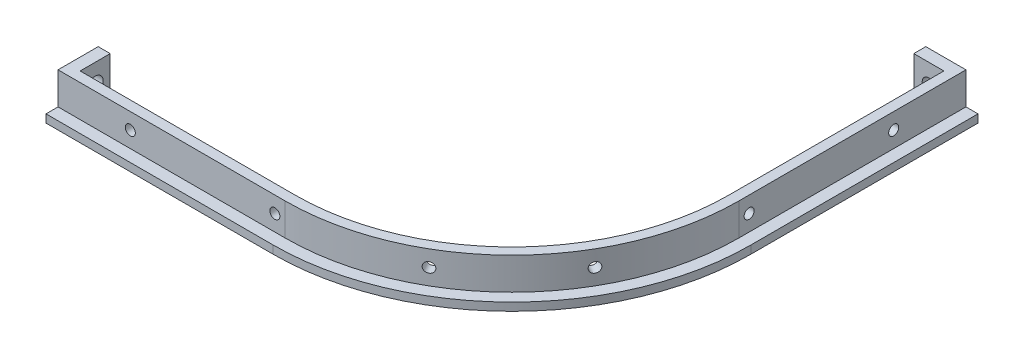
from build123d import *

# Parameters (mm, degrees)
BOSS_EXTRUDE1_DEPTH = 10
CUT_EXTRUDE1_START  = -1
SKETCH2_R           = 55.1
CUT_EXTRUDE1_DEPTH  = 1.1
CUT_EXTRUDE2_DEPTH  = 8
SKETCH4_R           = 2
CUT_EXTRUDE3_DEPTH  = 4
SKETCH5_R           = 1.65
CUT_EXTRUDE4_DEPTH  = 4
SKETCH7_R           = 1.25
CUT_EXTRUDE5_DEPTH  = 114.07
SKETCH9_R           = 1.25
CUT_EXTRUDE6_DEPTH  = 134.776057092


with BuildPart() as part:
    # Sketch1 → Boss-Extrude1 (new body)
    with BuildSketch(Plane(origin=(0, 0, 0), x_dir=(1, 0, 0), z_dir=(0, 1, 0))):
        with BuildLine():
            Line((0, -116.07), (56.57, -116.07))
            ThreePointArc((56.57, -116.07), (98.642853481, -98.642853481), (116.07, -56.57))
            Line((116.07, -56.57), (116.07, 0))
            Line((116.07, 0), (103.07, 0))
            Line((103.07, 0), (103.07, -3))
            Line((103.07, -3), (110.57, -3))
            Line((110.57, -3), (110.57, -56.57))
            ThreePointArc((110.57, -56.57), (94.753766184, -94.753766184), (56.57, -110.57))
            Line((56.57, -110.57), (3, -110.57))
            Line((3, -110.57), (3, -103.07))
            Line((3, -103.07), (0, -103.07))
            Line((0, -103.07), (0, -116.07))
        make_face()
    extrude(amount=BOSS_EXTRUDE1_DEPTH)

    # Sketch2 → Cut-Extrude1 (cut)
    with BuildSketch(Plane(origin=(0, 10, 0), x_dir=(1, 0, 0), z_dir=(0, 1, 0)).offset(CUT_EXTRUDE1_START)):
        with Locations((56.57, -56.57)):
            Circle(SKETCH2_R)
    extrude(amount=-CUT_EXTRUDE1_DEPTH, mode=Mode.SUBTRACT)

    # Sketch3 → Cut-Extrude2 (cut)
    with BuildSketch(Plane(origin=(0, 10, 0), x_dir=(1, 0, 0), z_dir=(0, 1, 0))):
        with BuildLine():
            Line((113.07, -56.57), (113.07, 0))
            Line((113.07, 0), (116.07, 0))
            Line((116.07, 0), (116.07, -56.57))
            ThreePointArc((116.07, -56.57), (98.642853481, -98.642853481), (56.57, -116.07))
            Line((56.57, -116.07), (0, -116.07))
            Line((0, -116.07), (0, -113.07))
            Line((0, -113.07), (56.57, -113.07))
            ThreePointArc((56.57, -113.07), (96.521533137, -96.521533137), (113.07, -56.57))
        make_face()
    extrude(amount=-CUT_EXTRUDE2_DEPTH, mode=Mode.SUBTRACT)

    # Sketch4 → Cut-Extrude3 (cut, through all)
    with BuildSketch(Plane(origin=(3, 0, 0), x_dir=(0, 0, -1), z_dir=(1, 0, 0))):
        with Locations((-106.82, 5)):
            Circle(SKETCH4_R)
    extrude(amount=-CUT_EXTRUDE3_DEPTH, mode=Mode.SUBTRACT)

    # Sketch5 → Cut-Extrude4 (cut, through all)
    with BuildSketch(Plane.XY.offset(3)):
        with Locations((106.82, 5)):
            Circle(SKETCH5_R)
    extrude(amount=-CUT_EXTRUDE4_DEPTH, mode=Mode.SUBTRACT)

    # Sketch7 → Cut-Extrude5 (cut, through all)
    with BuildSketch(Plane.XY.offset(113.07)):
        with Locations((18, 6)):
            Circle(SKETCH7_R)
        with Locations((54, 6)):
            Circle(SKETCH7_R)
    cut_extrude5 = extrude(amount=-CUT_EXTRUDE5_DEPTH, mode=Mode.SUBTRACT)

    # Sketch9 → Cut-Extrude6 (cut, through all)
    with BuildSketch(Plane(origin=(66.888028546, 0, 115.85346386), x_dir=(-0.866025404, 0, 0.5), z_dir=(-0.5, 0, -0.866025404))):
        with Locations((-20.706057092, 6)):
            Circle(SKETCH9_R)
    cut_extrude6 = extrude(amount=CUT_EXTRUDE6_DEPTH, mode=Mode.SUBTRACT)

    # Mirror1: Cut-Extrude5, Cut-Extrude6 across plane
    add(cut_extrude5.mirror(Plane(origin=(0, 0, 0), x_dir=(0.707106781, 0, 0.707106781), z_dir=(-0.707106781, 0, 0.707106781))), mode=Mode.SUBTRACT)
    add(cut_extrude6.mirror(Plane(origin=(0, 0, 0), x_dir=(0.707106781, 0, 0.707106781), z_dir=(-0.707106781, 0, 0.707106781))), mode=Mode.SUBTRACT)


solid = part.part
